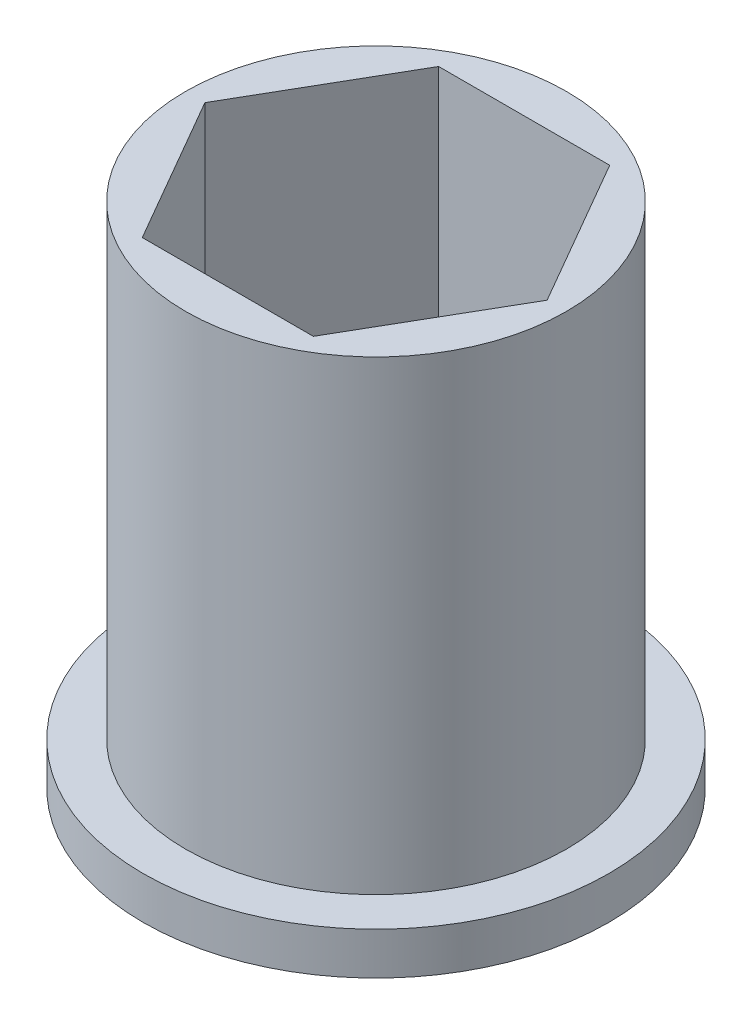
from build123d import *

# Parameters (mm, degrees)
SKETCH2_R           = 4.5
BOSS_EXTRUDE1_DEPTH = 12
SKETCH4_R           = 5.5
SKETCH4_R_2         = 4.5
BOSS_EXTRUDE3_DEPTH = 1


with BuildPart() as part:
    # Sketch2 → Boss-Extrude1 (new body)
    with BuildSketch(Plane(origin=(0, 0, 0), x_dir=(1, 0, 0), z_dir=(0, 1, 0))):
        Circle(SKETCH2_R)
        Polygon((4.041451884, 0), (2.020725942, 3.5), (-2.020725942, 3.5), (-4.041451884, 0), (-2.020725942, -3.5), (2.020725942, -3.5), align=None, mode=Mode.SUBTRACT)
    extrude(amount=BOSS_EXTRUDE1_DEPTH)

    # Sketch4 → Boss-Extrude3 (add)
    with BuildSketch(Plane.XZ):
        Circle(SKETCH4_R)
        Circle(SKETCH4_R_2, mode=Mode.SUBTRACT)
    extrude(amount=-BOSS_EXTRUDE3_DEPTH)


solid = part.part
